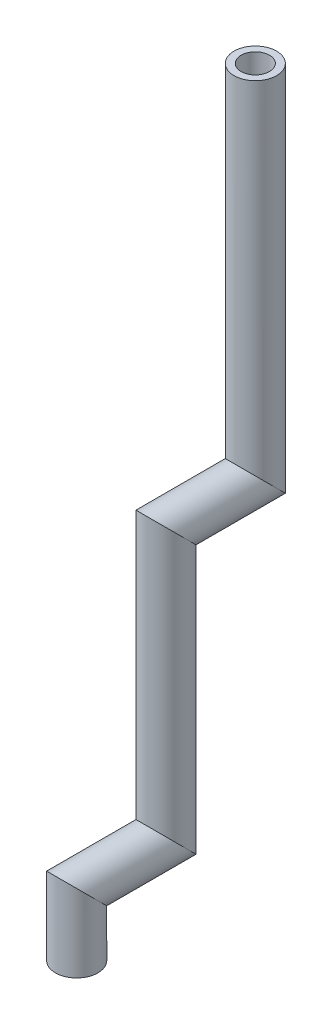
from build123d import *

# Parameters (mm, degrees)
SKETCH2_R   = 4.7625
SKETCH2_R_2 = 3.175


with BuildPart() as part:
    # Sweep2: sweep along a path in Sketch4
    with BuildLine(Plane(origin=(0, 0, 0), x_dir=(0, 0, -1), z_dir=(1, 0, 0))) as sweep2_path:
        Line((8, 0), (8, 14))
        Line((8, 14), (28, 14))
        Line((28, 14), (28, 74))
        Line((28, 74), (48, 74))
        Line((48, 74), (48, 154))
    # Sketch2 → Sweep2 (sweep)
    with BuildSketch(Plane(origin=(0, 0, 0), x_dir=(1, 0, 0), z_dir=(0, 1, 0))):
        with Locations((0, 8)):
            Circle(SKETCH2_R)
        with Locations((0, 8)):
            Circle(SKETCH2_R_2, mode=Mode.SUBTRACT)
    sweep(path=sweep2_path.line, transition=Transition.RIGHT)


solid = part.part
